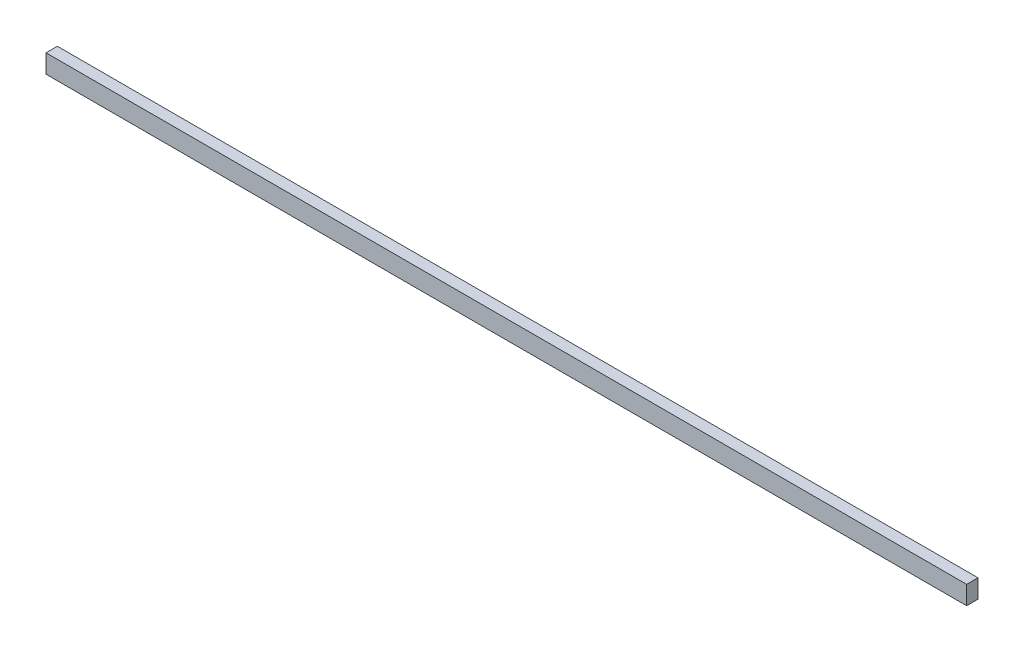
from build123d import *

# Parameters (mm, degrees)
SKETCH1_W           = 472.77
SKETCH1_H           = 9.525
BOSS_EXTRUDE1_DEPTH = 5.83


with BuildPart() as part:
    # Sketch1 → Boss-Extrude1 (new body)
    with BuildSketch(Plane.XY):
        with Locations((236.385, 4.7625)):
            Rectangle(SKETCH1_W, SKETCH1_H)
    extrude(amount=BOSS_EXTRUDE1_DEPTH)


solid = part.part
